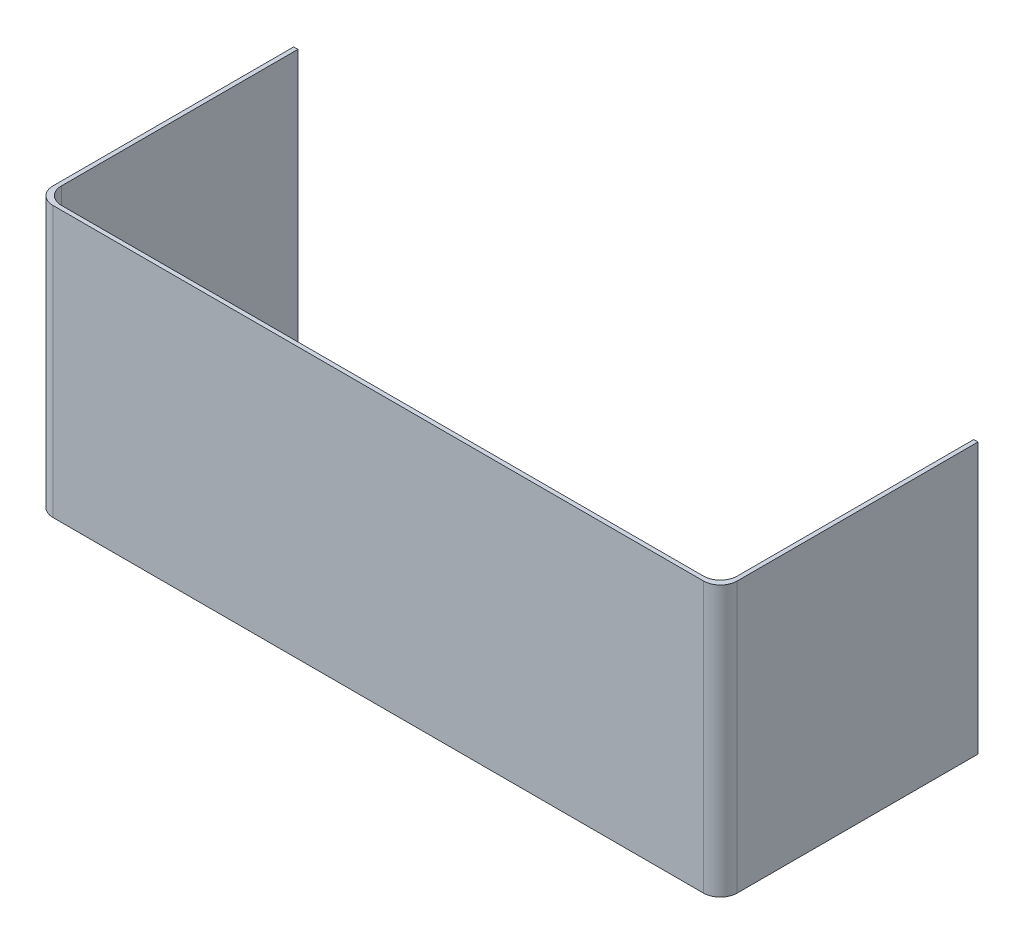
from build123d import *

# Parameters (mm, degrees)
BOSS_EXTRUDE1_DEPTH = 50.8
FILLET1_R           = 3.175


with BuildPart() as part:
    # Sketch1 → Boss-Extrude1 (new body)
    with BuildSketch(Plane(origin=(0, 0, 0), x_dir=(1, 0, 0), z_dir=(0, 1, 0))):
        Polygon((-64.29375, 47.625), (-63.5, 47.625), (-63.5, 0), (63.5, 0), (63.5, 47.625), (64.29375, 47.625), (64.29375, -0.79375), (-64.29375, -0.79375), align=None)
    extrude(amount=BOSS_EXTRUDE1_DEPTH)

    # Fillet1
    fillet1_edges = [part.edges().sort_by_distance(p)[0] for p in [
        (-63.5, 25.4, 0),
        (63.5, 25.4, 0),
        (64.29375, 25.4, 0.79375),
        (-64.29375, 25.4, 0.79375),
    ]]
    fillet(fillet1_edges, radius=FILLET1_R)


solid = part.part
